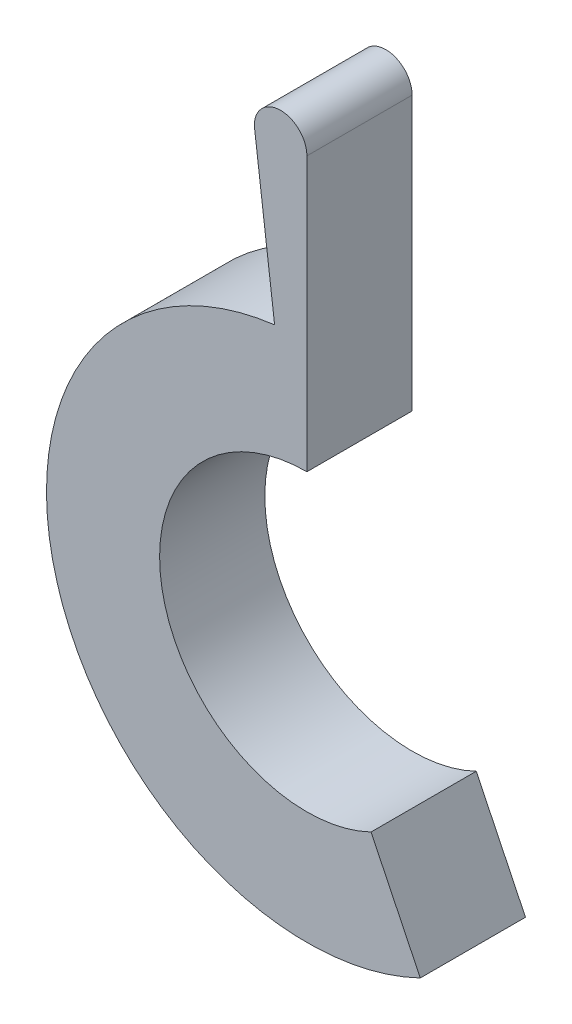
from build123d import *

# Parameters (mm, degrees)
RESSALTO_EXTRUS_O1_DEPTH = 10


with BuildPart() as part:
    # Esboço1 → Ressalto-extrusão1 (new body)
    with BuildSketch(Plane.XY):
        with BuildLine():
            Line((0, 14), (0, 20))
            Line((0, 20), (0, 40))
            ThreePointArc((0, 40), (-2.5, 42.5), (-5, 40))
            Line((-5, 40), (-4.923076923, 39.384615385))
            Line((-4.923076923, 39.384615385), (-3.069859681, 24.558877449))
            ThreePointArc((-3.069859681, 24.558877449), (-23.734852986, -7.015643501), (10.775337309, -22.281261317))
            Line((10.775337309, -22.281261317), (6.095140296, -12.603541755))
            ThreePointArc((6.095140296, -12.603541755), (-13.646420494, -3.126532858), (0, 14))
        make_face()
    extrude(amount=RESSALTO_EXTRUS_O1_DEPTH)


solid = part.part
